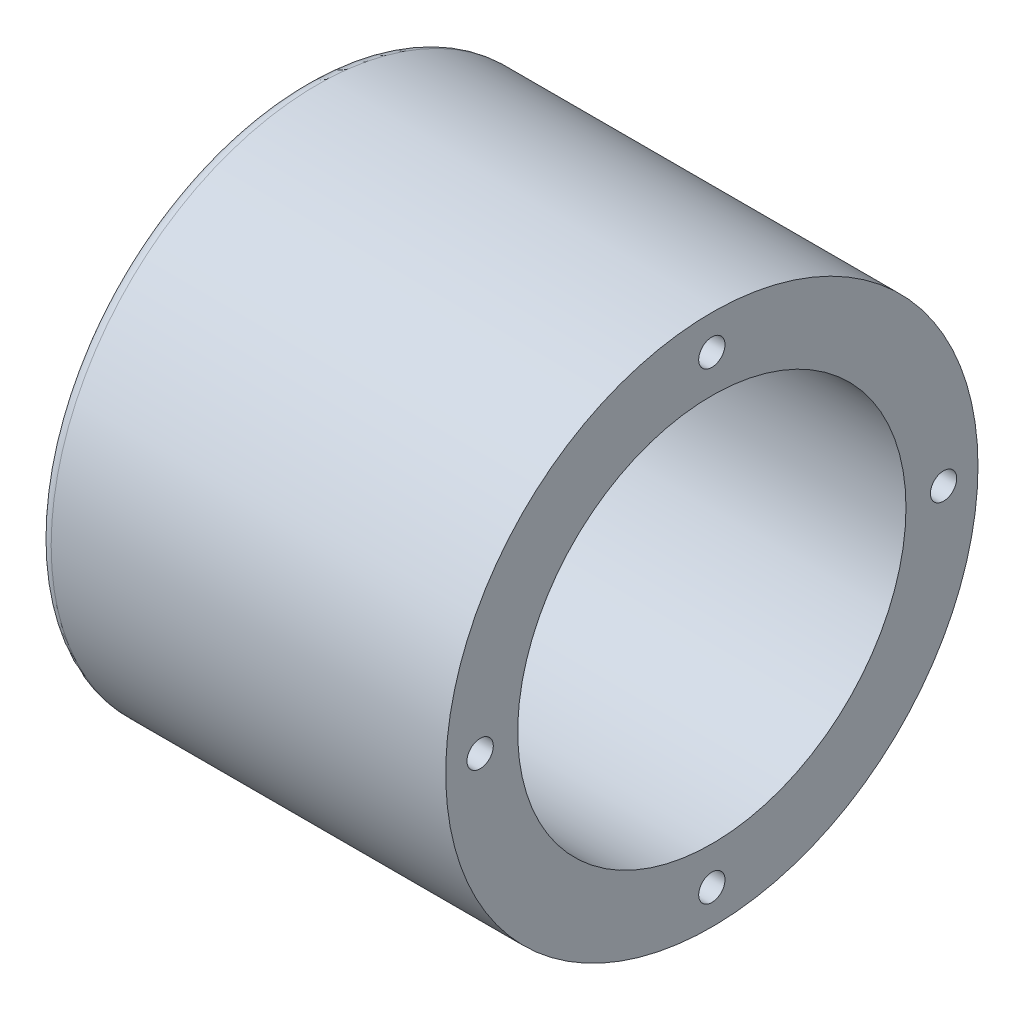
from build123d import *

# Parameters (mm, degrees)
FILLET1_R         = 2
CHAMFER1_SIZE     = 1
CIRPATTERN1_COUNT = 4


with BuildPart() as part:
    # Sketch1 → Revolve1 (revolve)
    with BuildSketch(Plane.XY):
        Polygon((-32.5, 42.5), (32.5, 42.5), (32.5, 31), (-28.5, 31), (-28.5, 28.5), (-32.5, 28.5), align=None)
    revolve(axis=Axis((88.99, 0, 0), (-1, 0, 0)))

    # Fillet1
    fillet1_edges = [part.edges().sort_by_distance(p)[0] for p in [
        (-32.5, -42.5, 0),
    ]]
    fillet(fillet1_edges, radius=FILLET1_R)

    # Chamfer1
    chamfer1_edges = [part.edges().sort_by_distance(p)[0] for p in [
        (-32.5, -28.5, 0),
    ]]
    chamfer(chamfer1_edges, length=CHAMFER1_SIZE)

    # Sketch5 → Tap Drill for M5x0.8 Tap1 (revolve, cut)
    with BuildSketch(Plane(origin=(32.5, 37, 0), x_dir=(0, 0, -1), z_dir=(0, 1, 0))):
        Polygon((0, 0), (0, 21.2618073), (2.1, 20), (2.1, 0), align=None)
    tap_drill_for_m5x0_8_tap1 = revolve(axis=Axis((38.85, 37, 0), (-1, 0, 0)), mode=Mode.SUBTRACT)

    # CirPattern1: Tap Drill for M5x0.8 Tap1 ×4 about axis
    cirpattern1_axis = Axis((88.99, 0, 0), (-1, 0, 0))
    for i in range(1, CIRPATTERN1_COUNT):
        add(tap_drill_for_m5x0_8_tap1.rotate(cirpattern1_axis, i * 360 / CIRPATTERN1_COUNT), mode=Mode.SUBTRACT)


solid = part.part
